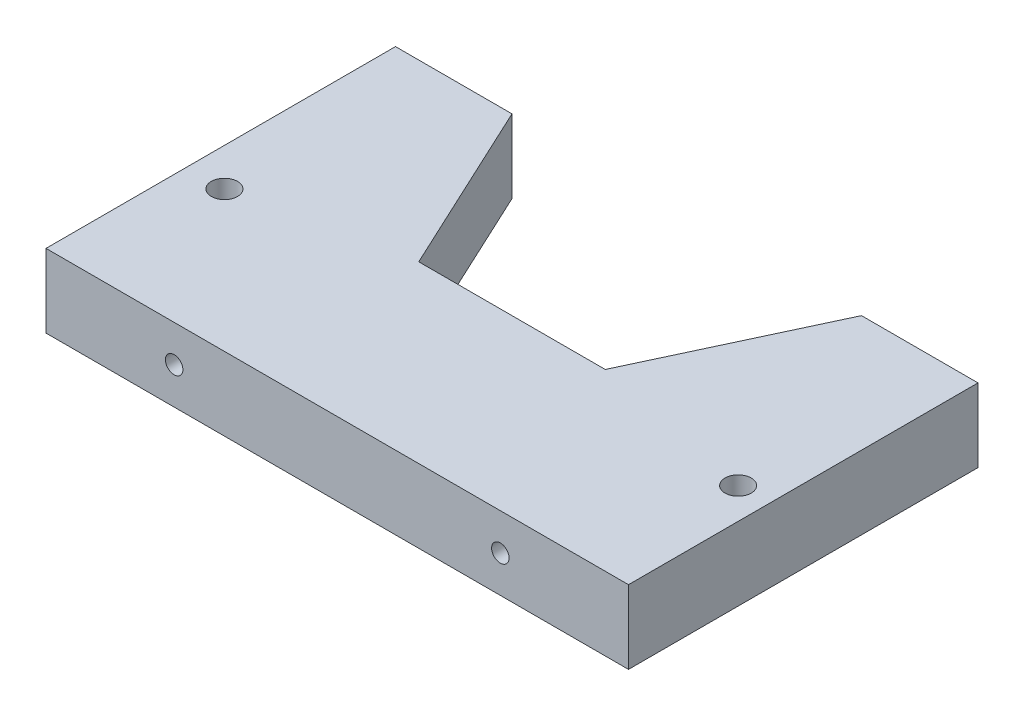
from build123d import *

# Parameters (mm, degrees)
BOSS_EXTRUDE1_DEPTH = 12.6
SKETCH2_R           = 1.5
CUT_EXTRUDE1_DEPTH  = 20
CUT_EXTRUDE2_REACH  = 14.6
SKETCH3_R           = 2.25


with BuildPart() as part:
    # Sketch1 → Boss-Extrude1 (new body)
    with BuildSketch(Plane(origin=(0, 0, 0), x_dir=(1, 0, 0), z_dir=(0, 1, 0))):
        Polygon((-30, 30), (-16.00813249, 0), (16.00813249, 0), (30, 30), (50, 30), (50, -30), (-50, -30), (-50, 30), align=None)
    extrude(amount=BOSS_EXTRUDE1_DEPTH)

    # Sketch2 → Cut-Extrude1 (cut)
    with BuildSketch(Plane.XY.offset(30)):
        with Locations((-28, 6.3)):
            Circle(SKETCH2_R)
        with Locations((28, 6.3)):
            Circle(SKETCH2_R)
    extrude(amount=-CUT_EXTRUDE1_DEPTH, mode=Mode.SUBTRACT)

    # Sketch3 → Cut-Extrude2 (cut, up to next)
    with BuildSketch(Plane.XZ, mode=Mode.PRIVATE) as cut_extrude2_sk1:
        with Locations((44.671841303, 5.85113754)):
            Circle(SKETCH3_R)
    cut_extrude2_tool1 = extrude(cut_extrude2_sk1.sketch, amount=-CUT_EXTRUDE2_REACH, mode=Mode.PRIVATE) & part.part
    add(cut_extrude2_tool1.solids().sort_by_distance((44.671841, 0, 5.851138))[0], mode=Mode.SUBTRACT)
    # Sketch3 → Cut-Extrude2 (cut, up to next)
    with BuildSketch(Plane.XZ, mode=Mode.PRIVATE) as cut_extrude2_sk2:
        with Locations((-43.519626776, 5.85113754)):
            Circle(SKETCH3_R)
    cut_extrude2_tool2 = extrude(cut_extrude2_sk2.sketch, amount=-CUT_EXTRUDE2_REACH, mode=Mode.PRIVATE) & part.part
    add(cut_extrude2_tool2.solids().sort_by_distance((-43.519627, 0, 5.851138))[0], mode=Mode.SUBTRACT)


solid = part.part
